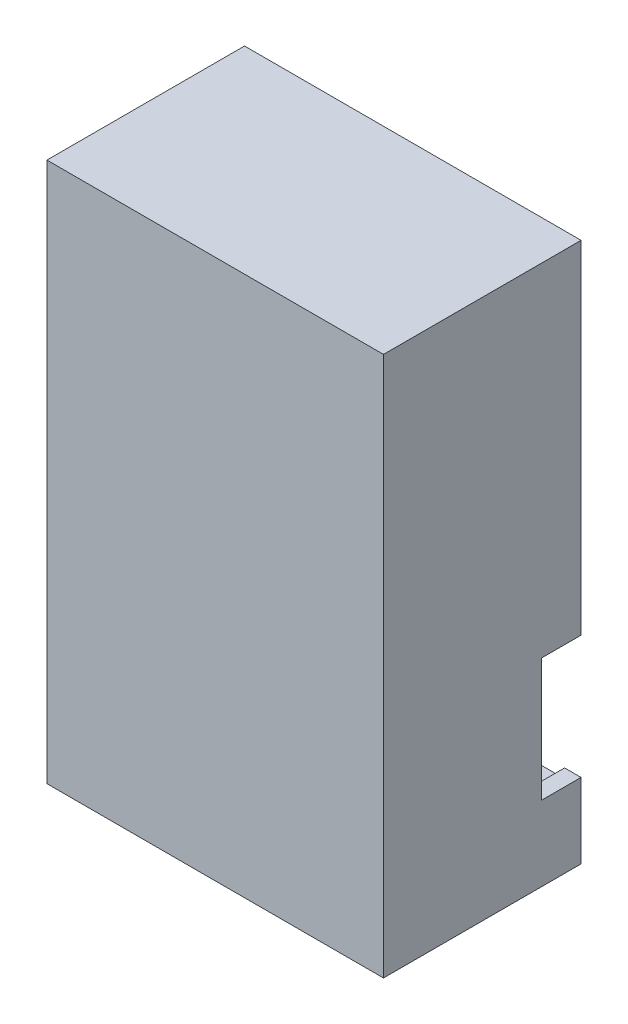
from build123d import *

# Parameters (mm, degrees)
SKETCH1_W           = 51.1
SKETCH1_H           = 82
SKETCH1_R           = 1.45
BOSS_EXTRUDE1_DEPTH = 5
BOSS_EXTRUDE2_START = 5
SKETCH2_W           = 51.1
SKETCH2_H           = 82
SKETCH2_W_2         = 46.1
SKETCH2_H_2         = 77
BOSS_EXTRUDE2_DEPTH = 23
SKETCH4_W           = 2
SKETCH4_H           = 82
BOSS_EXTRUDE3_DEPTH = 51.1
SKETCH5_W           = 2.5
SKETCH5_H           = 18.7
CUT_EXTRUDE1_DEPTH  = 6
BOSS_EXTRUDE4_START = 5
SKETCH6_W           = 8.1
SKETCH6_H           = 18.7
BOSS_EXTRUDE4_DEPTH = 2
SKETCH7_W           = 8.1
SKETCH7_H           = 2
BOSS_EXTRUDE5_DEPTH = 7


with BuildPart() as part:
    # Sketch1 → Boss-Extrude1 (new body)
    with BuildSketch(Plane.XY):
        with Locations((25.55, 41)):
            Rectangle(SKETCH1_W, SKETCH1_H)
        with Locations((6, 76)):
            Circle(SKETCH1_R, mode=Mode.SUBTRACT)
        with Locations((45.1, 76)):
            Circle(SKETCH1_R, mode=Mode.SUBTRACT)
        with Locations((45.1, 6)):
            Circle(SKETCH1_R, mode=Mode.SUBTRACT)
        with Locations((6, 6)):
            Circle(SKETCH1_R, mode=Mode.SUBTRACT)
        with BuildLine():
            Line((6, 72.05), (2.5, 72.05))
            Line((2.5, 72.05), (2.5, 9.95))
            Line((2.5, 9.95), (6, 9.95))
            ThreePointArc((6, 9.95), (8.793071786, 8.793071786), (9.95, 6))
            Line((9.95, 6), (9.95, 2.5))
            Line((9.95, 2.5), (41.15, 2.5))
            Line((41.15, 2.5), (41.15, 6))
            ThreePointArc((41.15, 6), (42.306928214, 8.793071786), (45.1, 9.95))
            Line((45.1, 9.95), (48.6, 9.95))
            Line((48.6, 9.95), (48.6, 72.05))
            Line((48.6, 72.05), (45.1, 72.05))
            ThreePointArc((45.1, 72.05), (42.306928214, 73.206928214), (41.15, 76))
            Line((41.15, 76), (41.15, 79.5))
            Line((41.15, 79.5), (9.95, 79.5))
            Line((9.95, 79.5), (9.95, 76))
            ThreePointArc((9.95, 76), (8.793071786, 73.206928214), (6, 72.05))
        make_face(mode=Mode.SUBTRACT)
    extrude(amount=BOSS_EXTRUDE1_DEPTH)

    # Sketch2 → Boss-Extrude2 (add)
    with BuildSketch(Plane.XY.offset(BOSS_EXTRUDE2_START)):
        with Locations((25.55, 41)):
            Rectangle(SKETCH2_W, SKETCH2_H)
        with Locations((25.55, 41)):
            Rectangle(SKETCH2_W_2, SKETCH2_H_2, mode=Mode.SUBTRACT)
    extrude(amount=BOSS_EXTRUDE2_DEPTH)

    # Sketch4 → Boss-Extrude3 (add)
    with BuildSketch(Plane(origin=(0, 0, 0), x_dir=(0, 0, -1), z_dir=(1, 0, 0))):
        with Locations((-29, 41)):
            Rectangle(SKETCH4_W, SKETCH4_H)
    extrude(amount=BOSS_EXTRUDE3_DEPTH)

    # Sketch5 → Cut-Extrude1 (cut)
    with BuildSketch(Plane.XY):
        with Locations((49.85, 20.726044427)):
            Rectangle(SKETCH5_W, SKETCH5_H)
    extrude(amount=CUT_EXTRUDE1_DEPTH, mode=Mode.SUBTRACT)

    # Sketch6 → Boss-Extrude4 (add)
    with BuildSketch(Plane.XY.offset(BOSS_EXTRUDE4_START)):
        with Locations((6.55, 20.726044427)):
            Rectangle(SKETCH6_W, SKETCH6_H)
    extrude(amount=BOSS_EXTRUDE4_DEPTH)

    # Sketch7 → Boss-Extrude5 (add)
    with BuildSketch(Plane.XY):
        with Locations((6.55, 31.076044427)):
            Rectangle(SKETCH7_W, SKETCH7_H)
        with Locations((6.55, 10.376044427)):
            Rectangle(SKETCH7_W, SKETCH7_H)
    extrude(amount=BOSS_EXTRUDE5_DEPTH)


solid = part.part
